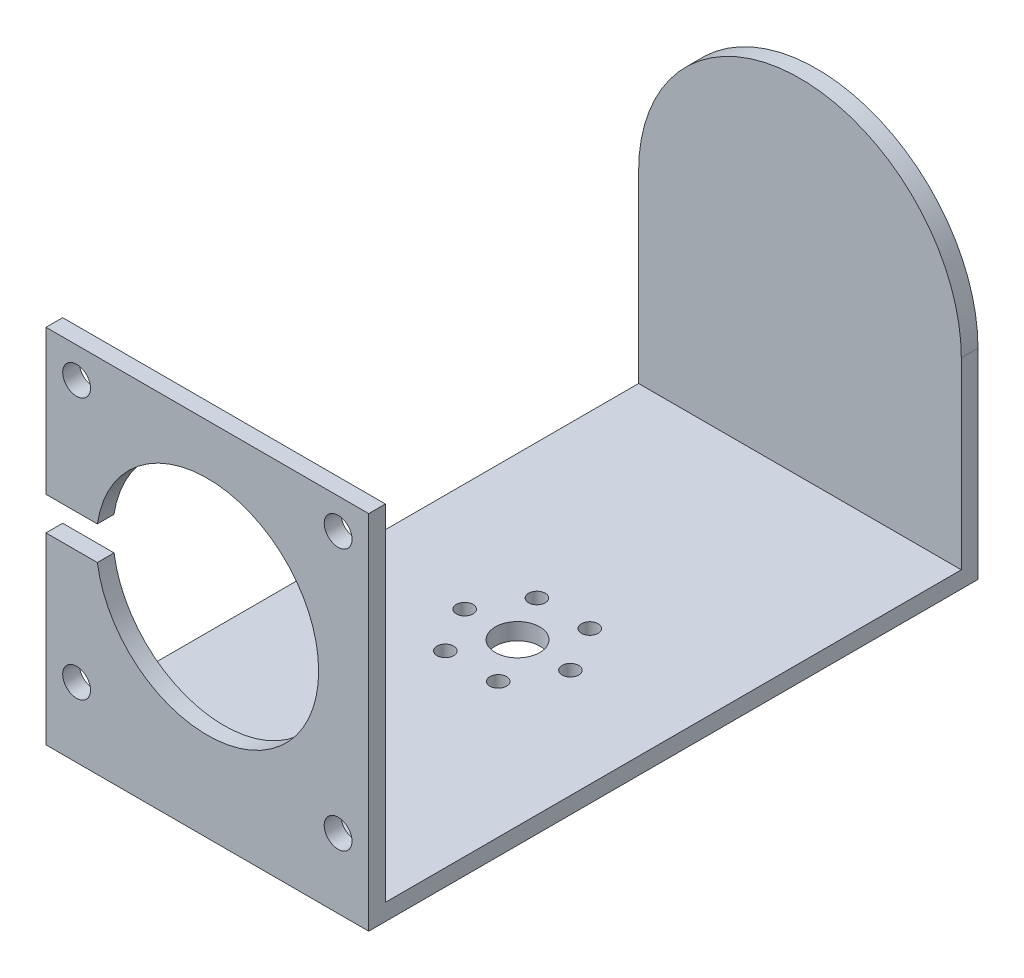
from build123d import *

# Parameters (mm, degrees)
BOSS_EXTRUDE1_DEPTH = 58
SKETCH2_R           = 2.5
SKETCH2_R_2         = 20
CUT_EXTRUDE1_DEPTH  = 58
CUT_EXTRUDE2_DEPTH  = 58
CUT_EXTRUDE3_DEPTH  = 58
SKETCH5_R           = 2.95
BOSS_EXTRUDE2_DEPTH = 8
SKETCH7_W           = 29
SKETCH7_H           = 6
CUT_EXTRUDE5_DEPTH  = 10
SKETCH25_R          = 4
CUT_EXTRUDE6_DEPTH  = 10
SKETCH26_W          = 103.5
SKETCH26_H          = 2
CUT_EXTRUDE7_DEPTH  = 90
SKETCH29_R          = 1.5
CUT_EXTRUDE8_DEPTH  = 10


with BuildPart() as part:
    # Sketch1 → Boss-Extrude1 (new body)
    with BuildSketch(Plane(origin=(0, 0, 0), x_dir=(0, 0, -1), z_dir=(1, 0, 0))):
        Polygon((-73.351671883, 30.400809615), (-73.351671883, -29.599190385), (30.148328117, -29.599190385), (30.148328117, 30.400809615), (33.148328117, 30.400809615), (33.148328117, -34.599190385), (-76.351671883, -34.599190385), (-76.351671883, 30.400809615), align=None)
    extrude(amount=BOSS_EXTRUDE1_DEPTH)

    # Sketch2 → Cut-Extrude1 (cut)
    with BuildSketch(Plane.XY.offset(76.351671883)):
        with Locations((5.5, 24.900809615)):
            Circle(SKETCH2_R)
        with Locations((52.5, 24.900809615)):
            Circle(SKETCH2_R)
        with Locations((52.5, -22.099190385)):
            Circle(SKETCH2_R)
        with Locations((5.5, -22.099190385)):
            Circle(SKETCH2_R)
        with Locations((29, 1.400809615)):
            Circle(SKETCH2_R_2)
    extrude(amount=-CUT_EXTRUDE1_DEPTH, mode=Mode.SUBTRACT)

    # Sketch3 → Cut-Extrude2 (cut)
    with BuildSketch(Plane(origin=(0, 0, -33.148328117), x_dir=(-1, 0, 0), z_dir=(0, 0, -1))):
        with BuildLine():
            Line((-29, 30.400809615), (-58, 30.400809615))
            Line((-58, 30.400809615), (-58, 1.400809615))
            ThreePointArc((-58, 1.400809615), (-49.506096654, 21.90690627), (-29, 30.400809615))
        make_face()
    extrude(amount=-CUT_EXTRUDE2_DEPTH, mode=Mode.SUBTRACT)

    # Sketch4 → Cut-Extrude3 (cut)
    with BuildSketch(Plane(origin=(0, 0, -33.148328117), x_dir=(-1, 0, 0), z_dir=(0, 0, -1))):
        with BuildLine():
            Line((-29, 30.400809615), (0, 30.400809615))
            Line((0, 30.400809615), (0, 1.400809615))
            ThreePointArc((0, 1.400809615), (-8.493903346, 21.90690627), (-29, 30.400809615))
        make_face()
    extrude(amount=-CUT_EXTRUDE3_DEPTH, mode=Mode.SUBTRACT)

    # Sketch5 → Boss-Extrude2 (add)
    with BuildSketch(Plane(origin=(0, 0, -33.148328117), x_dir=(-1, 0, 0), z_dir=(0, 0, -1))):
        with Locations((-29, 1.400809615)):
            Circle(SKETCH5_R)
    extrude(amount=BOSS_EXTRUDE2_DEPTH)

    # Sketch7 → Cut-Extrude5 (cut)
    with BuildSketch(Plane.XY.offset(76.351671883)):
        with Locations((14.5, 1.400809615)):
            Rectangle(SKETCH7_W, SKETCH7_H)
    extrude(amount=-CUT_EXTRUDE5_DEPTH, mode=Mode.SUBTRACT)

    # Sketch25 → Cut-Extrude6 (cut)
    with BuildSketch(Plane.XZ.offset(34.599190385)):
        with Locations((29, 20.601671883)):
            Circle(SKETCH25_R)
    extrude(amount=-CUT_EXTRUDE6_DEPTH, mode=Mode.SUBTRACT)

    # Sketch26 → Cut-Extrude7 (cut)
    with BuildSketch(Plane(origin=(58, 0, 0), x_dir=(0, 0, -1), z_dir=(1, 0, 0))):
        with Locations((-21.601671883, -30.599190385)):
            Rectangle(SKETCH26_W, SKETCH26_H)
    extrude(amount=-CUT_EXTRUDE7_DEPTH, mode=Mode.SUBTRACT)

    # Sketch29 → Cut-Extrude8 (cut)
    with BuildSketch(Plane(origin=(0, -31.599190385, 0), x_dir=(1, 0, 0), z_dir=(0, 1, 0))):
        with Locations((19.5, -20.601671883)):
            Circle(SKETCH29_R)
        with Locations((24.25, -12.374430547)):
            Circle(SKETCH29_R)
        with Locations((33.75, -12.374430547)):
            Circle(SKETCH29_R)
        with Locations((38.5, -20.601671883)):
            Circle(SKETCH29_R)
        with Locations((33.75, -28.828913219)):
            Circle(SKETCH29_R)
        with Locations((24.25, -28.828913219)):
            Circle(SKETCH29_R)
    extrude(amount=-CUT_EXTRUDE8_DEPTH, mode=Mode.SUBTRACT)


solid = part.part
